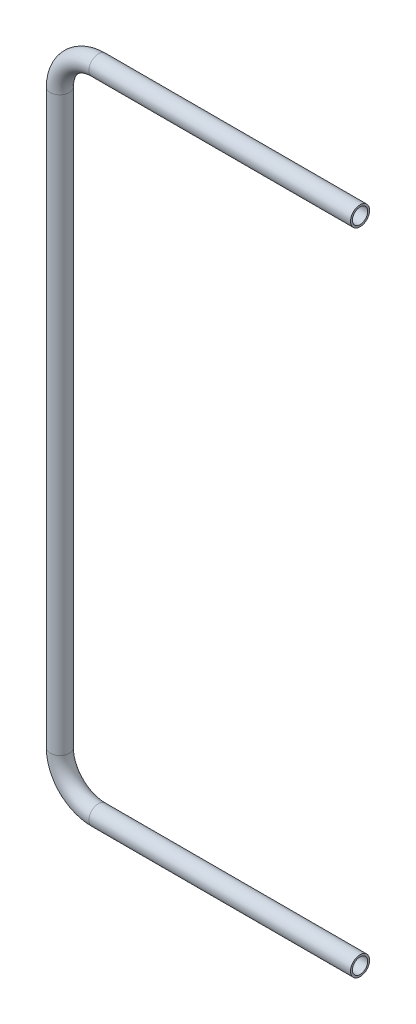
from build123d import *

# Parameters (mm, degrees)
SKETCH2_R   = 16.7005
SKETCH2_R_2 = 13.335


with BuildPart() as part:
    # Sweep1: sweep along a path in Sketch1
    with BuildLine(Plane.XY) as sweep1_path:
        Line((0, 0), (-457.2, 0))
        ThreePointArc((-457.2, 0), (-504.930061283, 19.770438717), (-524.7005, 67.5005))
        Line((-524.7005, 67.5005), (-524.7005, 1067.562))
        ThreePointArc((-524.7005, 1067.562), (-504.930061283, 1115.292061283), (-457.2, 1135.0625))
        Line((-457.2, 1135.0625), (0, 1135.0625))
    # Sketch2 → Sweep1 (sweep)
    with BuildSketch(Plane(origin=(0, 0, 0), x_dir=(0, 0, -1), z_dir=(1, 0, 0))):
        Circle(SKETCH2_R)
        Circle(SKETCH2_R_2, mode=Mode.SUBTRACT)
    sweep(path=sweep1_path.line)


solid = part.part
